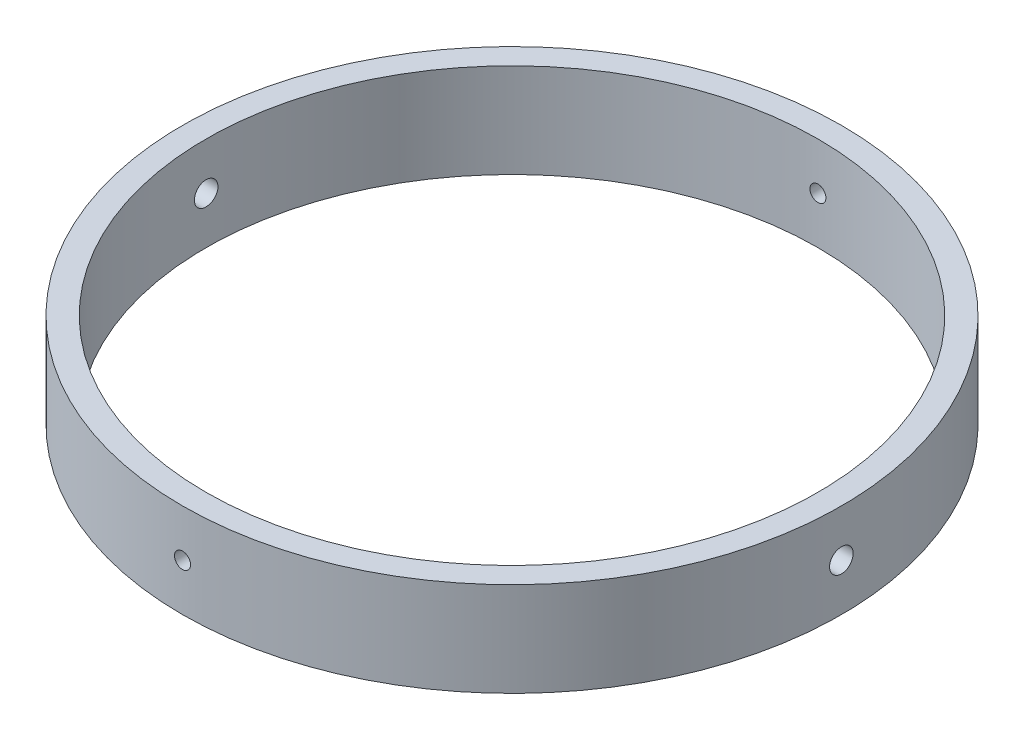
from build123d import *

# Parameters (mm, degrees)
SKETCH1_R               = 88.9
SKETCH1_R_2             = 82.55
BOSS_EXTRUDE1_DEPTH     = 25.4
SKETCH2_R               = 3.175
CUT_EXTRUDE1_DEPTH      = 89.9
CUT_EXTRUDE1_DEPTH_BACK = 89.9
SKETCH3_R               = 2.159
CUT_EXTRUDE2_DEPTH      = 89.9000001
CUT_EXTRUDE2_DEPTH_BACK = 89.9000001


with BuildPart() as part:
    # Sketch1 → Boss-Extrude1 (new body)
    with BuildSketch(Plane(origin=(0, 0, 0), x_dir=(1, 0, 0), z_dir=(0, 1, 0))):
        Circle(SKETCH1_R)
        Circle(SKETCH1_R_2, mode=Mode.SUBTRACT)
    extrude(amount=BOSS_EXTRUDE1_DEPTH)

    # Sketch2 → Cut-Extrude1 (cut, two sides)
    with BuildSketch(Plane(origin=(0, 0, 0), x_dir=(0, 0, -1), z_dir=(1, 0, 0))) as cut_extrude1_sk:
        with Locations((0, 12.7)):
            Circle(SKETCH2_R)
    extrude(amount=CUT_EXTRUDE1_DEPTH, mode=Mode.SUBTRACT)
    extrude(cut_extrude1_sk.sketch, amount=-CUT_EXTRUDE1_DEPTH_BACK, mode=Mode.SUBTRACT)

    # Sketch3 → Cut-Extrude2 (cut, two sides)
    with BuildSketch(Plane.XY) as cut_extrude2_sk:
        with Locations((0, 12.7)):
            Circle(SKETCH3_R)
    extrude(amount=CUT_EXTRUDE2_DEPTH, mode=Mode.SUBTRACT)
    extrude(cut_extrude2_sk.sketch, amount=-CUT_EXTRUDE2_DEPTH_BACK, mode=Mode.SUBTRACT)


solid = part.part
